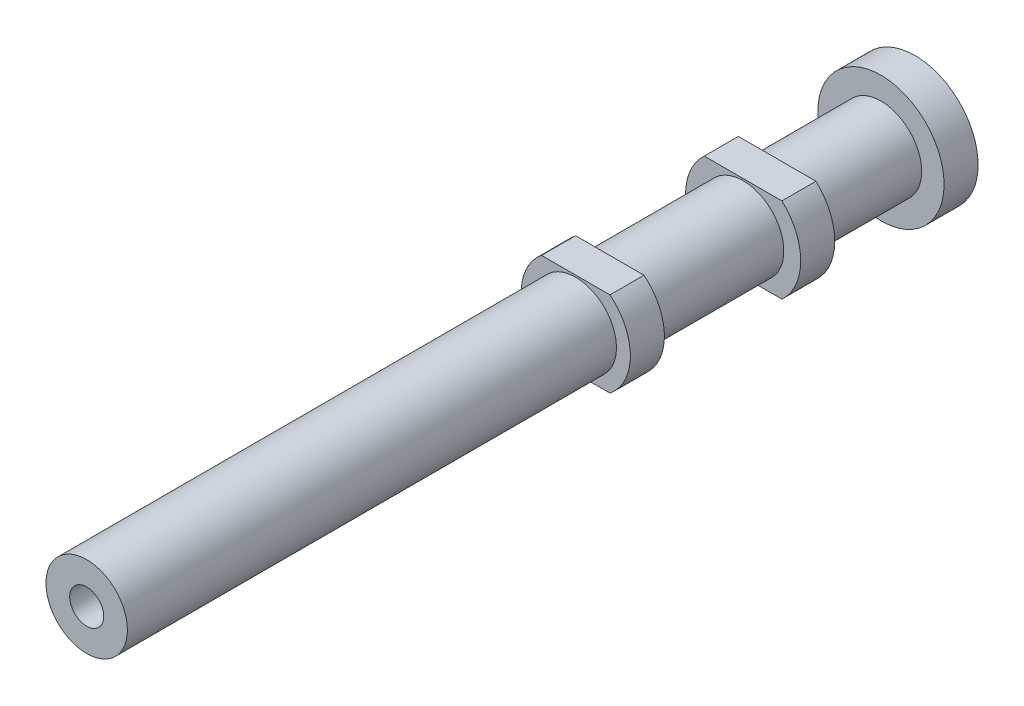
from build123d import *

# Parameters (mm, degrees)
SKETCH1_R           = 1.435
BOSS_EXTRUDE1_DEPTH = 14.6
SKETCH2_R           = 0.6
CUT_EXTRUDE1_DEPTH  = 5
SKETCH3_W           = 0.49
SKETCH3_H           = 1.2
SKETCH3_W_2         = 0.595
SKETCH3_W_3         = 0.79
SKETCH4_W           = 4
SKETCH4_H           = 1
CUT_EXTRUDE2_DEPTH  = 24.34


with BuildPart() as part:
    # Sketch1 → Boss-Extrude1 (new body, symmetric)
    with BuildSketch(Plane.XY):
        Circle(SKETCH1_R)
    extrude(amount=BOSS_EXTRUDE1_DEPTH, both=True)

    # Sketch2 → Cut-Extrude1 (cut)
    with BuildSketch(Plane.XY.offset(14.6)):
        Circle(SKETCH2_R)
    extrude(amount=-CUT_EXTRUDE1_DEPTH, mode=Mode.SUBTRACT)

    # Sketch3 → Revolve1 (revolve)
    with BuildSketch(Plane(origin=(0, 0, 0), x_dir=(1, 0, 0), z_dir=(0, 1, 0))):
        with Locations((1.68, 3.24)):
            Rectangle(SKETCH3_W, SKETCH3_H)
        with Locations((1.7325, 9.14)):
            Rectangle(SKETCH3_W_2, SKETCH3_H)
        with Locations((1.83, 14)):
            Rectangle(SKETCH3_W_3, SKETCH3_H)
    revolve(axis=Axis((0, 0, -14.6), (0, 0, 1)))

    # Sketch4 → Cut-Extrude2 (cut)
    with BuildSketch(Plane.XY.offset(14.6)):
        with Locations((0, 2)):
            Rectangle(SKETCH4_W, SKETCH4_H)
        with Locations((0, -2)):
            Rectangle(SKETCH4_W, SKETCH4_H)
    extrude(amount=-CUT_EXTRUDE2_DEPTH, mode=Mode.SUBTRACT)


solid = part.part
